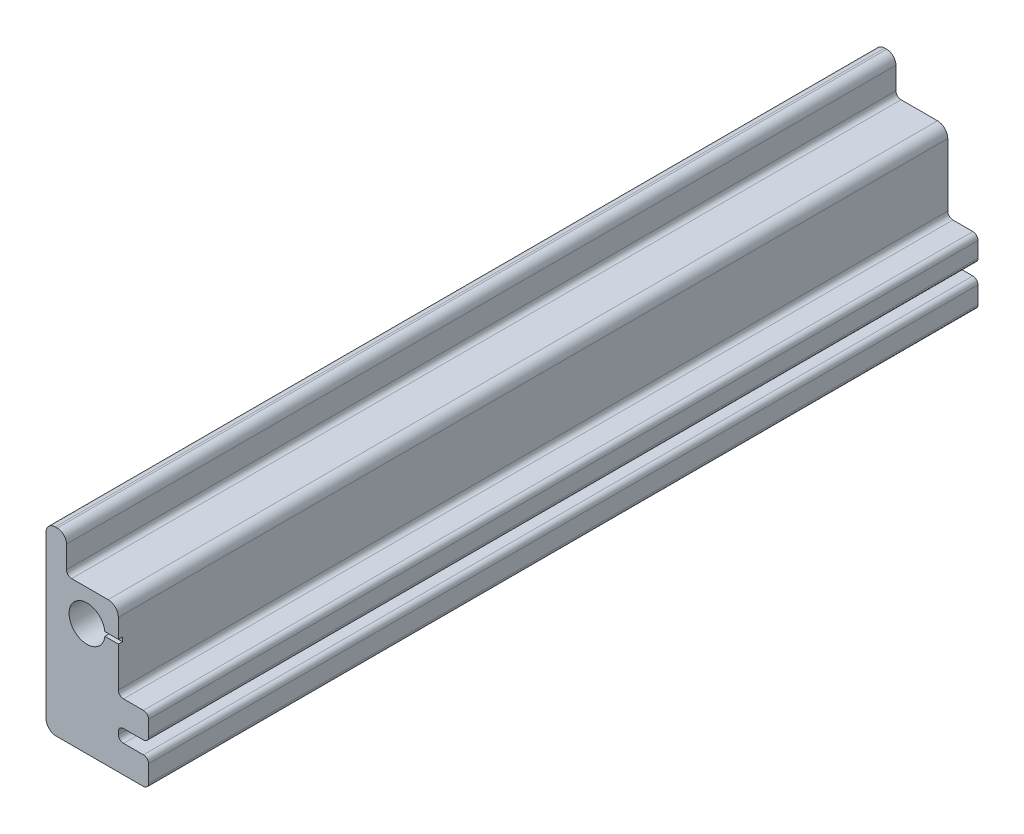
from build123d import *

# Parameters (mm, degrees)
SKETCH1_R           = 11.1125
BOSS_EXTRUDE1_DEPTH = 513.461
SKETCH2_W           = 20.65782
SKETCH2_H           = 2.54
CUT_EXTRUDE1_DEPTH  = 2.54


with BuildPart() as part:
    # Sketch1 → Boss-Extrude1 (new body)
    with BuildSketch(Plane.XY):
        with BuildLine():
            Line((34.925, -69.85), (-19.05, -69.85))
            ThreePointArc((-19.05, -69.85), (-23.540128061, -67.990128061), (-25.4, -63.5))
            Line((-25.4, -63.5), (-25.4, 36.297819962))
            ThreePointArc((-25.4, 36.297819962), (-23.726115254, 40.338935216), (-19.685, 42.012819962))
            Line((-19.685, 42.012819962), (-18.415, 42.012819962))
            ThreePointArc((-18.415, 42.012819962), (-14.373884746, 40.338935216), (-12.7, 36.297819962))
            Line((-12.7, 36.297819962), (-12.7, 22.56282))
            ThreePointArc((-12.7, 22.56282), (-11.77006403, 20.31775597), (-9.525, 19.38782))
            Line((-9.525, 19.38782), (13.03782, 19.38782))
            ThreePointArc((13.03782, 19.38782), (17.527948061, 17.527948061), (19.38782, 13.03782))
            Line((19.38782, 13.03782), (19.38782, -25.872179904))
            ThreePointArc((19.38782, -25.872179904), (20.31775597, -28.117243934), (22.56282, -29.047179904))
            Line((22.56282, -29.047179904), (34.925, -29.047179904))
            ThreePointArc((34.925, -29.047179904), (37.17006403, -29.977115874), (38.1, -32.222179904))
            Line((38.1, -32.222179904), (38.1, -41.747179904))
            ThreePointArc((38.1, -41.747179904), (37.17006403, -43.992243934), (34.925, -44.922179904))
            Line((34.925, -44.922179904), (22.56282, -44.922179904))
            ThreePointArc((22.56282, -44.922179904), (20.31775597, -45.852115874), (19.38782, -48.097179904))
            Line((19.38782, -48.097179904), (19.38782, -49.684679904))
            ThreePointArc((19.38782, -49.684679904), (20.31775597, -51.929743934), (22.56282, -52.859679904))
            Line((22.56282, -52.859679904), (34.925, -52.859679904))
            ThreePointArc((34.925, -52.859679904), (37.17006403, -53.789615874), (38.1, -56.034679904))
            Line((38.1, -56.034679904), (38.1, -66.675))
            ThreePointArc((38.1, -66.675), (37.17006403, -68.92006403), (34.925, -69.85))
        make_face()
        Circle(SKETCH1_R, mode=Mode.SUBTRACT)
    extrude(amount=BOSS_EXTRUDE1_DEPTH)

    # Sketch2 → Cut-Extrude1 (cut)
    with BuildSketch(Plane.XY.offset(513.461)):
        with Locations((9.05891, 0)):
            Rectangle(SKETCH2_W, SKETCH2_H)
    extrude(amount=-CUT_EXTRUDE1_DEPTH, mode=Mode.SUBTRACT)


solid = part.part
